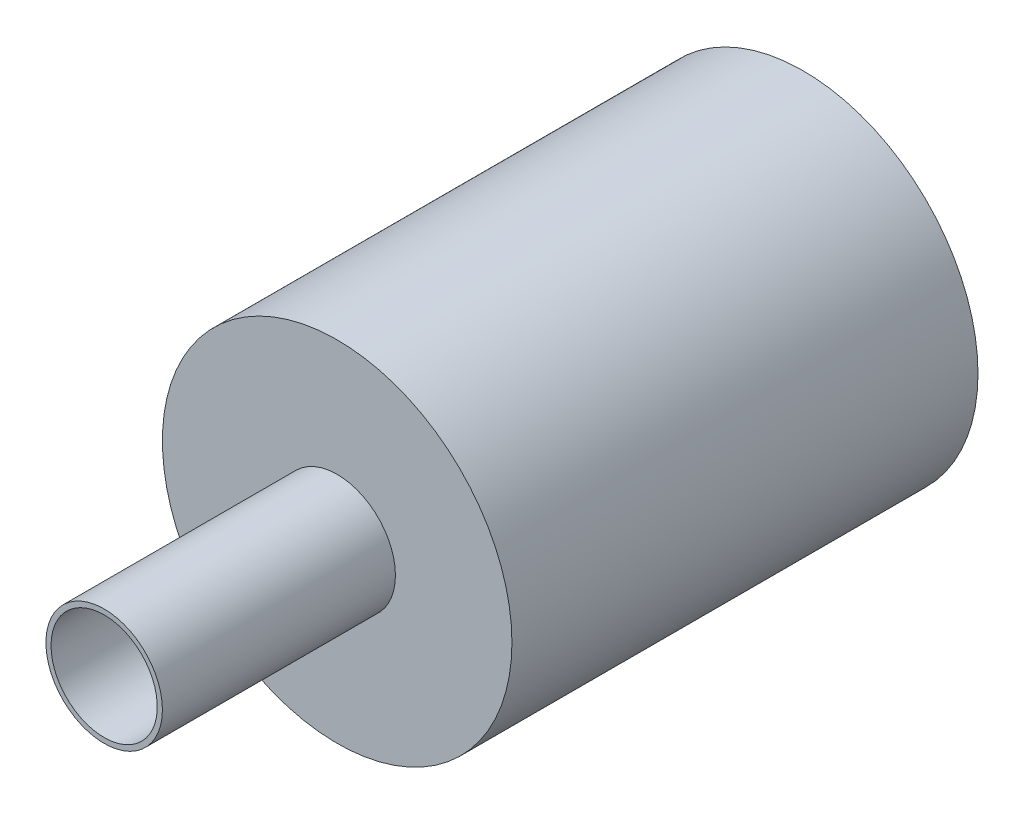
from build123d import *

# Parameters (mm, degrees)
SKETCH1_R                            = 9.525
BOSS_EXTRUDE1_DEPTH                  = 25.4
SKETCH2_R                            = 3.175
BOSS_EXTRUDE2_DEPTH                  = 12.7
F_1_0_228_DIAMETER_HOLE1_D           = 5.7912
F_35_64_0_54688_DIAMETER_HOLE1_D     = 13.890752
F_35_64_0_54688_DIAMETER_HOLE1_DEPTH = 18.796
F_35_64_0_54688_DIAMETER_HOLE1_TIP   = 4.173202923


with BuildPart() as part:
    # Sketch1 → Boss-Extrude1 (new body)
    with BuildSketch(Plane.XY):
        Circle(SKETCH1_R)
    extrude(amount=BOSS_EXTRUDE1_DEPTH)

    # Sketch2 → Boss-Extrude2 (add)
    with BuildSketch(Plane.XY.offset(25.4)):
        Circle(SKETCH2_R)
    extrude(amount=BOSS_EXTRUDE2_DEPTH)

    # #1 (0.228) Diameter Hole1 (through all)
    with Locations(Plane(origin=(0, 0, 0), x_dir=(-1, 0, 0), z_dir=(0, 0, -1))):
        with Locations((0, 0)):
            Hole(F_1_0_228_DIAMETER_HOLE1_D / 2)

    # 35/64 (0.54688) Diameter Hole1
    with Locations(Plane(origin=(0, 0, 0), x_dir=(-1, 0, 0), z_dir=(0, 0, -1))):
        with Locations((0, 0)):
            Hole(F_35_64_0_54688_DIAMETER_HOLE1_D / 2, depth=F_35_64_0_54688_DIAMETER_HOLE1_DEPTH)
            with Locations((0, 0, -(F_35_64_0_54688_DIAMETER_HOLE1_DEPTH + F_35_64_0_54688_DIAMETER_HOLE1_TIP / 2))):  # 118° drill point
                Cone(0, F_35_64_0_54688_DIAMETER_HOLE1_D / 2, F_35_64_0_54688_DIAMETER_HOLE1_TIP, mode=Mode.SUBTRACT)


solid = part.part
